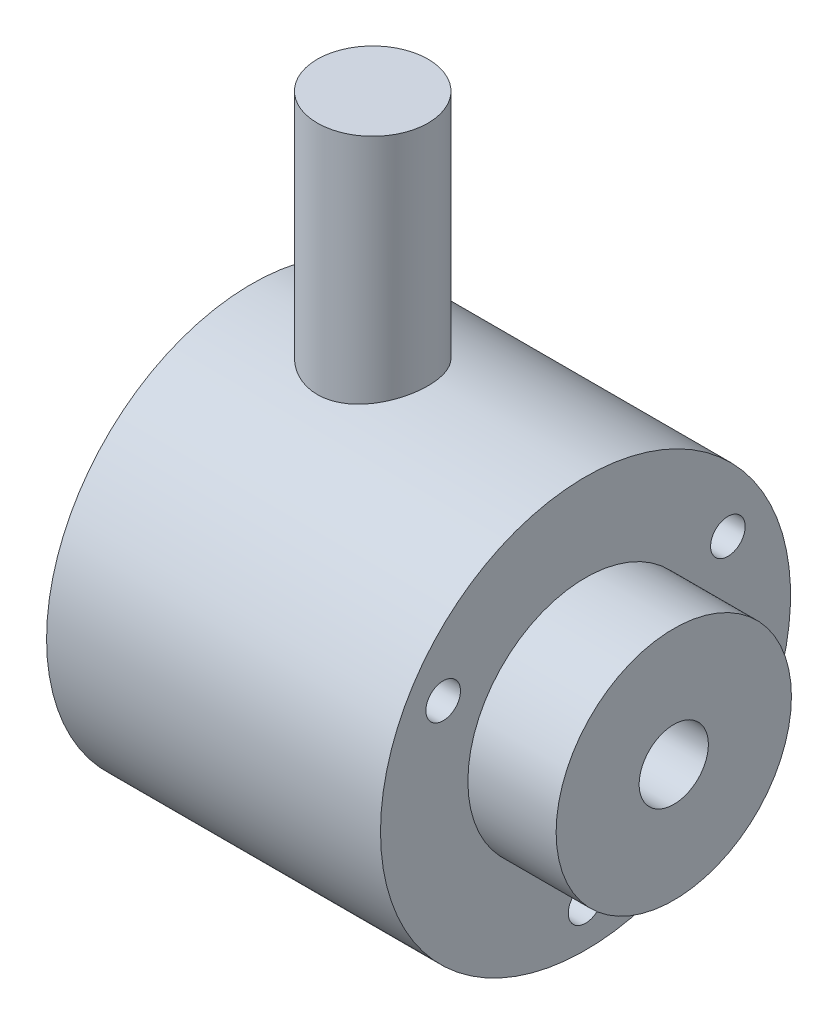
from build123d import *

# Parameters (mm, degrees)
ESQUISSE2_R             = 3.2
BOSS_EXTRU_1_DEPTH      = 25
ESQUISSE3_R             = 2
ENL_V_MAT_EXTRU_1_DEPTH = 14
ESQUISSE4_R             = 1
ENL_V_MAT_EXTRU_2_DEPTH = 4


with BuildPart() as part:
    # Esquisse1 → Révolution2 (revolve)
    with BuildSketch(Plane.XY):
        Polygon((0, 0), (24.4, 0), (24.4, 6.8), (19.3, 6.8), (19.3, 11.85), (0, 11.85), align=None)
    revolve(axis=Axis((0, 0, 0), (1, 0, 0)))

    # Esquisse2 → Boss.-Extru.1 (add)
    with BuildSketch(Plane(origin=(0, 0, 0), x_dir=(1, 0, 0), z_dir=(0, 1, 0))):
        with Locations((7, 0)):
            Circle(ESQUISSE2_R)
    extrude(amount=BOSS_EXTRU_1_DEPTH)

    # Esquisse3 → Enlèv. mat.-Extru.1 (cut)
    with BuildSketch(Plane(origin=(24.4, 0, 0), x_dir=(0, 0, -1), z_dir=(1, 0, 0))):
        Circle(ESQUISSE3_R)
    extrude(amount=-ENL_V_MAT_EXTRU_1_DEPTH, mode=Mode.SUBTRACT)

    # Esquisse4 → Enlèv. mat.-Extru.2 (cut)
    with BuildSketch(Plane(origin=(19.3, 0, 0), x_dir=(0, 0, -1), z_dir=(1, 0, 0))):
        with Locations((0, -9.5)):
            Circle(ESQUISSE4_R)
        with Locations((-8.227241336, 4.75)):
            Circle(ESQUISSE4_R)
        with Locations((8.227241336, 4.75)):
            Circle(ESQUISSE4_R)
    extrude(amount=-ENL_V_MAT_EXTRU_2_DEPTH, mode=Mode.SUBTRACT)


solid = part.part
